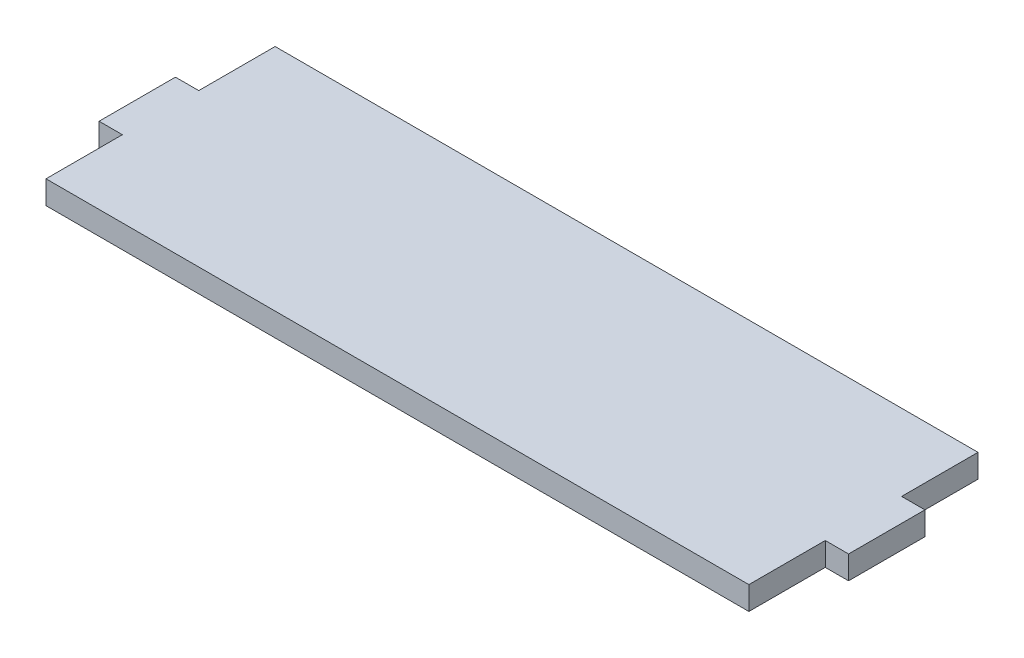
from build123d import *

# Parameters (mm, degrees)
SKETCH1_W           = 193
SKETCH1_H           = 59
BOSS_EXTRUDE1_DEPTH = 6
SKETCH1_3_W         = 6
SKETCH1_3_H         = 19.666666667
CUT_EXTRUDE1_DEPTH  = 7


with BuildPart() as part:
    # Sketch1 → Boss-Extrude1 (new body)
    with BuildSketch(Plane(origin=(0, 0, 0), x_dir=(1, 0, 0), z_dir=(0, 1, 0))):
        Rectangle(SKETCH1_W, SKETCH1_H)
    extrude(amount=BOSS_EXTRUDE1_DEPTH)

    # Sketch1_3 → Cut-Extrude1 (cut, through all)
    with BuildSketch(Plane(origin=(0, 0, 0), x_dir=(1, 0, 0), z_dir=(0, 1, 0))):
        with Locations((-93.5, -19.666666667)):
            Rectangle(SKETCH1_3_W, SKETCH1_3_H)
        with Locations((-93.5, 19.666666667)):
            Rectangle(SKETCH1_3_W, SKETCH1_3_H)
    cut_extrude1 = extrude(amount=CUT_EXTRUDE1_DEPTH, mode=Mode.SUBTRACT)

    # Mirror1: Cut-Extrude1 across plane
    add(cut_extrude1.mirror(Plane(origin=(0, 0, 0), x_dir=(0, 0, 1), z_dir=(1, 0, 0))), mode=Mode.SUBTRACT)


solid = part.part
